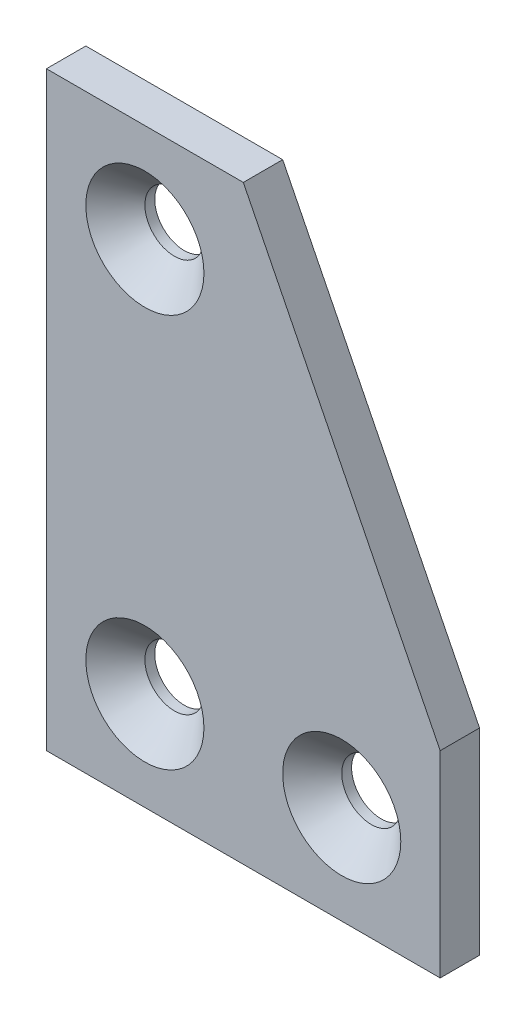
from build123d import *

# Parameters (mm, degrees)
BOSS_EXTRUDE1_DEPTH = 2
SKETCH2_R           = 3
CUT_EXTRUDE1_DEPTH  = 5
CHAMFER1_SIZE       = 3


with BuildPart() as part:
    # Sketch1 → Boss-Extrude1 (new body, symmetric)
    with BuildSketch(Plane.XY):
        Polygon((-20, -30), (-20, 30), (0, 30), (20, -10), (20, -30), align=None)
    extrude(amount=BOSS_EXTRUDE1_DEPTH, both=True)

    # Sketch2 → Cut-Extrude1 (cut, through all)
    with BuildSketch(Plane.XY.offset(2)):
        with Locations((-10, 20)):
            Circle(SKETCH2_R)
        with Locations((-10, -20)):
            Circle(SKETCH2_R)
        with Locations((10, -20)):
            Circle(SKETCH2_R)
    extrude(amount=-CUT_EXTRUDE1_DEPTH, mode=Mode.SUBTRACT)

    # Chamfer1
    chamfer1_edges = [part.edges().sort_by_distance(p)[0] for p in [
        (-13, 20, 2),
        (-13, -20, 2),
        (7, -20, 2),
    ]]
    chamfer(chamfer1_edges, length=CHAMFER1_SIZE)


solid = part.part
